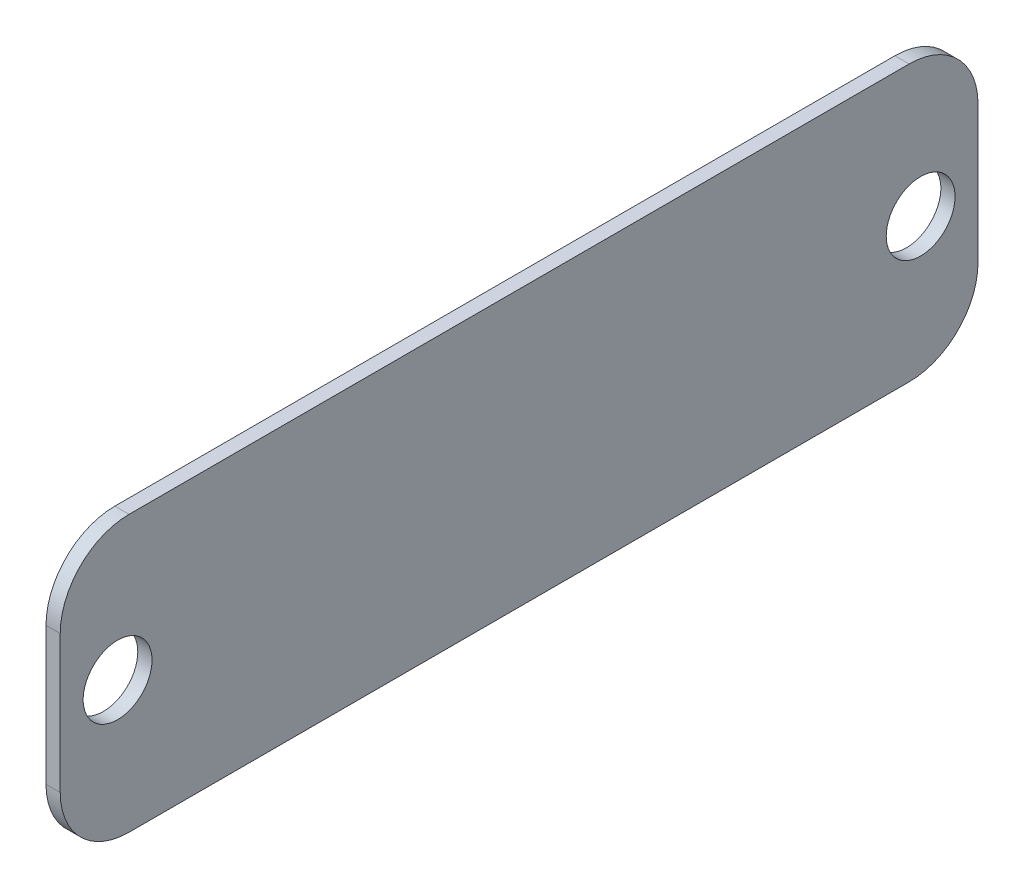
from build123d import *

# Parameters (mm, degrees)
CROQUIS1_W              = 200
CROQUIS1_H              = 60
SALIENTE_EXTRUIR1_DEPTH = 1.55
REDONDEO1_R             = 15
CROQUIS2_R              = 7.5
CORTAR_EXTRUIR1_DEPTH   = 3.1


with BuildPart() as part:
    # Croquis1 → Saliente-Extruir1 (new body, symmetric)
    with BuildSketch(Plane(origin=(0, 0, 0), x_dir=(0, 0, -1), z_dir=(1, 0, 0))):
        Rectangle(CROQUIS1_W, CROQUIS1_H)
    extrude(amount=SALIENTE_EXTRUIR1_DEPTH, both=True)

    # Redondeo1
    redondeo1_edges = [part.edges().sort_by_distance(p)[0] for p in [
        (0, -30, -100),
        (0, -30, 100),
        (0, 30, 100),
        (0, 30, -100),
    ]]
    fillet(redondeo1_edges, radius=REDONDEO1_R)

    # Croquis2 → Cortar-Extruir1 (cut)
    with BuildSketch(Plane(origin=(1.55, 0, 0), x_dir=(0, 0, -1), z_dir=(1, 0, 0))):
        with Locations((-87.5, 0)):
            Circle(CROQUIS2_R)
        with Locations((87.5, 0)):
            Circle(CROQUIS2_R)
    extrude(amount=-CORTAR_EXTRUIR1_DEPTH, mode=Mode.SUBTRACT)


solid = part.part
